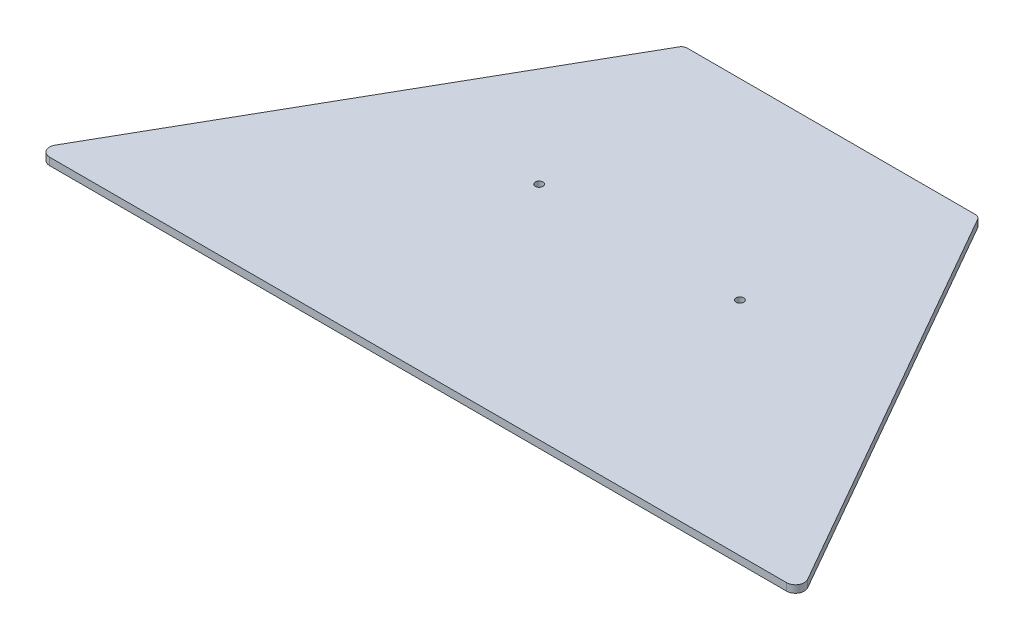
from build123d import *

# Parameters (mm, degrees)
BOSS_EXTRUDE1_DEPTH = 3.175
FILLET1_R           = 3.81
FILLET2_R           = 2.54
SKETCH2_R           = 1.651
CUT_EXTRUDE1_DEPTH  = 4.175


with BuildPart() as part:
    # Sketch1 → Boss-Extrude1 (new body)
    with BuildSketch(Plane(origin=(0, 0, 0), x_dir=(1, 0, 0), z_dir=(0, 1, 0))):
        Polygon((0, 0), (165.1, 0), (63.5, 177.8), (0, 177.8), align=None)
    boss_extrude1 = extrude(amount=BOSS_EXTRUDE1_DEPTH)

    # Mirror1: Boss-Extrude1 across plane
    add(boss_extrude1.mirror(Plane(origin=(0, 0, 0), x_dir=(0, 0, 1), z_dir=(1, 0, 0))))

    # Fillet1
    fillet1_edges = [part.edges().sort_by_distance(p)[0] for p in [
        (-165.1, 1.5875, 0),
        (165.1, 1.5875, 0),
    ]]
    fillet(fillet1_edges, radius=FILLET1_R)

    # Fillet2
    fillet2_edges = [part.edges().sort_by_distance(p)[0] for p in [
        (-63.5, 1.5875, -177.8),
        (63.5, 1.5875, -177.8),
    ]]
    fillet(fillet2_edges, radius=FILLET2_R)

    # Sketch2 → Cut-Extrude1 (cut, through all)
    with BuildSketch(Plane(origin=(0, 3.175, 0), x_dir=(1, 0, 0), z_dir=(0, 1, 0))):
        with Locations((43.18, 95.25)):
            Circle(SKETCH2_R)
    cut_extrude1 = extrude(amount=-CUT_EXTRUDE1_DEPTH, mode=Mode.SUBTRACT)

    # Mirror2: Cut-Extrude1 across plane
    add(cut_extrude1.mirror(Plane(origin=(0, 0, 0), x_dir=(0, 0, 1), z_dir=(1, 0, 0))), mode=Mode.SUBTRACT)


solid = part.part
